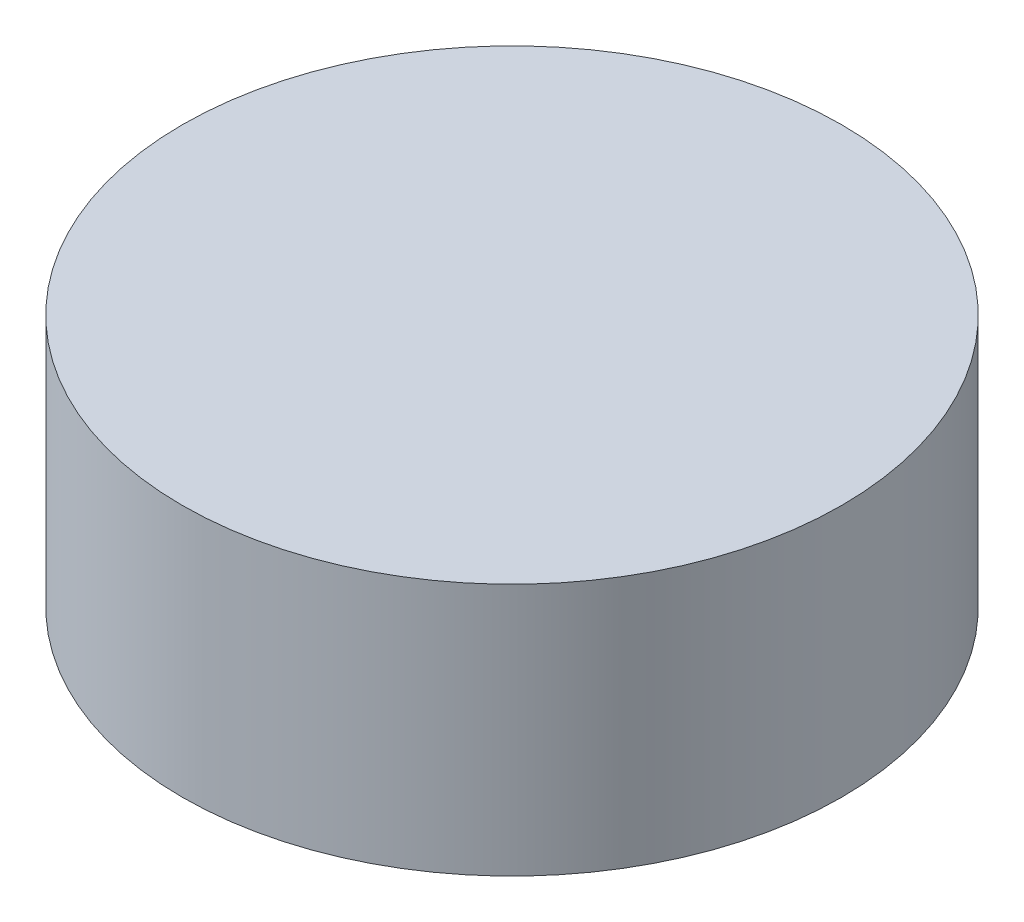
from build123d import *

# Parameters (mm, degrees)
SKETCH1_R           = 30
BOSS_EXTRUDE1_DEPTH = 23


with BuildPart() as part:
    # Sketch1 → Boss-Extrude1 (new body)
    with BuildSketch(Plane(origin=(0, 0, 0), x_dir=(1, 0, 0), z_dir=(0, 1, 0))):
        Circle(SKETCH1_R)
    extrude(amount=BOSS_EXTRUDE1_DEPTH)


solid = part.part
